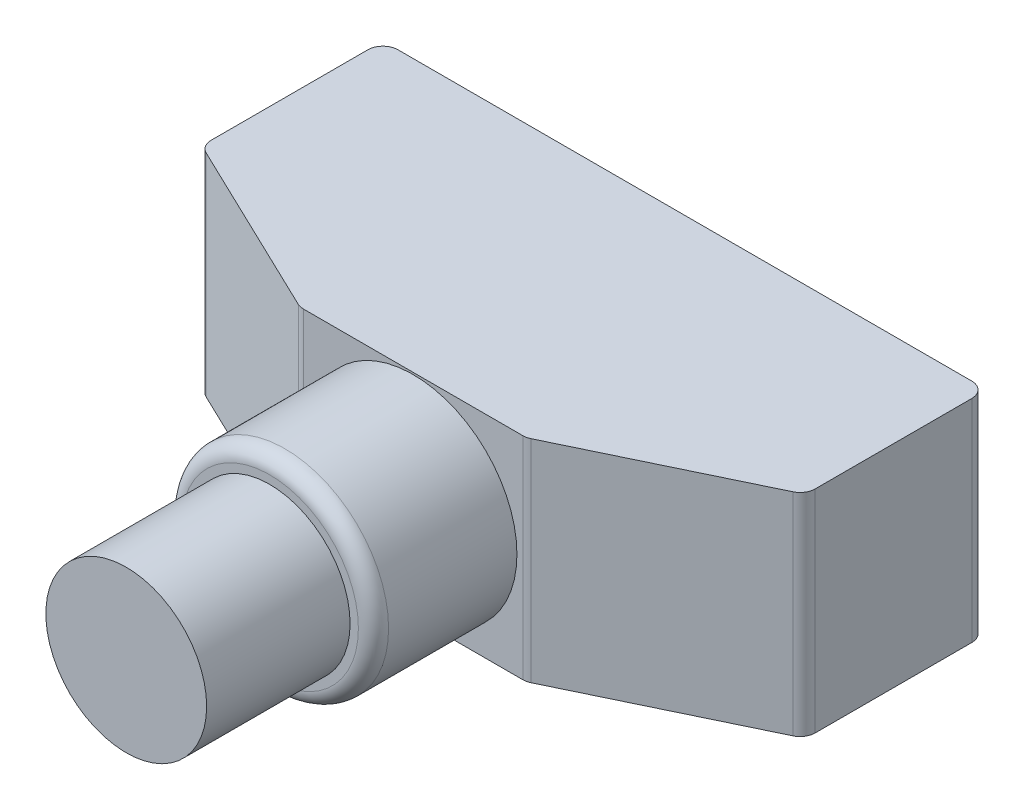
from build123d import *

# Parameters (mm, degrees)
BOSS_EXTRUDE1_DEPTH = 14
SKETCH2_R           = 6.875
BOSS_EXTRUDE2_DEPTH = 9.5
SKETCH3_R           = 5.325
BOSS_EXTRUDE3_DEPTH = 9.5
FILLET1_R           = 1


with BuildPart() as part:
    # Sketch1 → Boss-Extrude1 (new body)
    with BuildSketch(Plane(origin=(0, 0, 0), x_dir=(1, 0, 0), z_dir=(0, 1, 0))):
        Polygon((0, 0), (0, -12), (12.5, -18), (27.5, -18), (40, -12), (40, 0), align=None)
    extrude(amount=BOSS_EXTRUDE1_DEPTH)

    # Sketch2 → Boss-Extrude2 (add)
    with BuildSketch(Plane.XY.offset(18)):
        with Locations((20, 7)):
            Circle(SKETCH2_R)
    extrude(amount=BOSS_EXTRUDE2_DEPTH)

    # Sketch3 → Boss-Extrude3 (add)
    with BuildSketch(Plane.XY.offset(27.5)):
        with Locations((20, 7)):
            Circle(SKETCH3_R)
    extrude(amount=BOSS_EXTRUDE3_DEPTH)

    # Fillet1
    fillet1_edges = [part.edges().sort_by_distance(p)[0] for p in [
        (0, 7, 0),
        (40, 7, 0),
        (40, 7, 12),
        (27.5, 7, 18),
        (12.5, 7, 18),
        (0, 7, 12),
        (13.125, 7, 27.5),
    ]]
    fillet(fillet1_edges, radius=FILLET1_R)


solid = part.part
